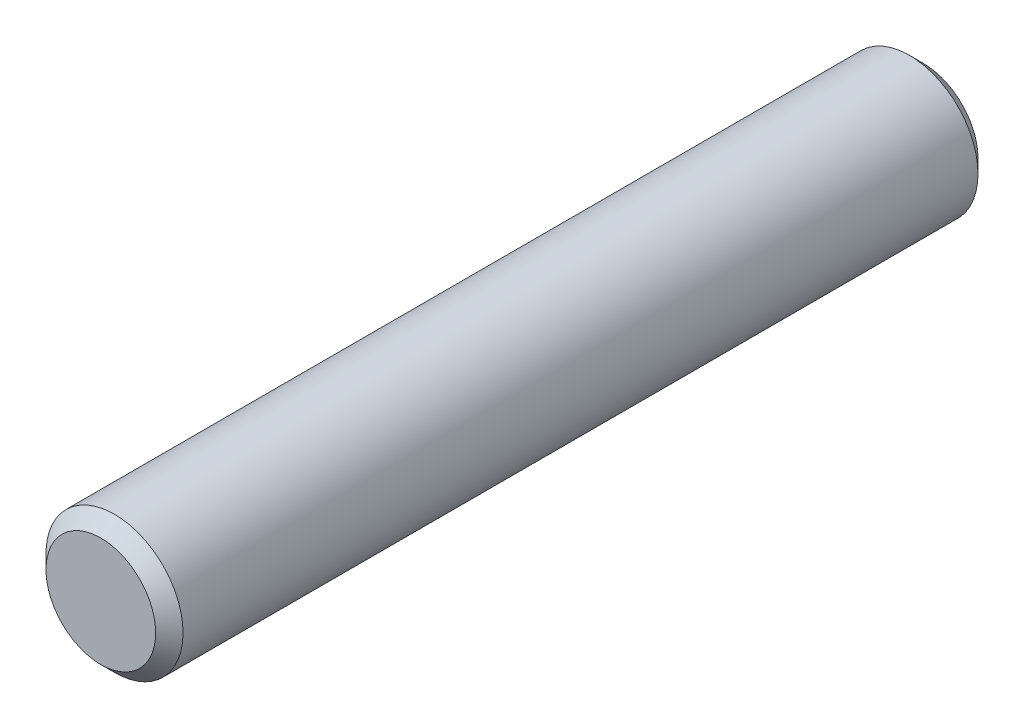
from build123d import *

# Parameters (mm, degrees)
SKETCH1_R           = 2.5
BOSS_EXTRUDE1_DEPTH = 15
CHAMFER1_SIZE       = 0.5


with BuildPart() as part:
    # Sketch1 → Boss-Extrude1 (new body, symmetric)
    with BuildSketch(Plane.XY):
        Circle(SKETCH1_R)
    extrude(amount=BOSS_EXTRUDE1_DEPTH, both=True)

    # Chamfer1
    chamfer1_edges = [part.edges().sort_by_distance(p)[0] for p in [
        (-2.5, 0, -15),
        (-2.5, 0, 15),
    ]]
    chamfer(chamfer1_edges, length=CHAMFER1_SIZE)


solid = part.part
